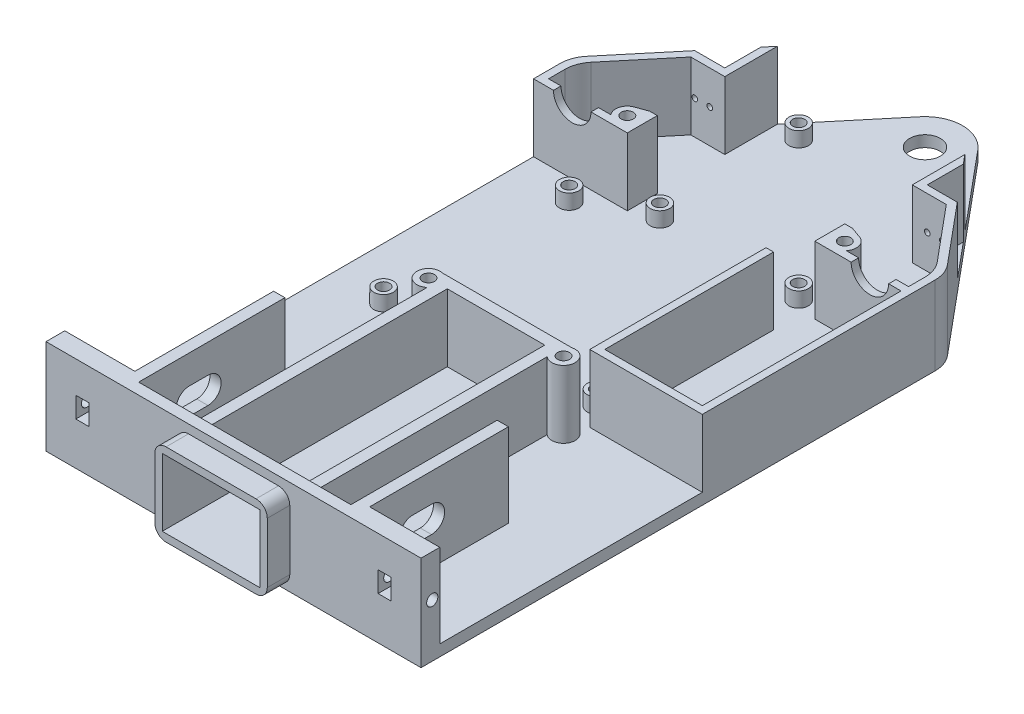
from build123d import *

# Parameters (mm, degrees)
SKETCH1_W            = 100
SKETCH1_H            = 140
BOSS_EXTRUDE1_DEPTH  = 3
BOSS_EXTRUDE2_DEPTH  = 22.3
SKETCH4_W            = 3.5
SKETCH4_H            = 5.5
CUT_EXTRUDE2_DEPTH   = 5
CUT_EXTRUDE1_START   = -3
SKETCH3_R            = 1.5
CUT_EXTRUDE1_DEPTH   = 22.7
BOSS_EXTRUDE3_DEPTH  = 18
BOSS_EXTRUDE4_DEPTH  = 3
SKETCH7_W            = 26
SKETCH7_H            = 18
BOSS_EXTRUDE5_DEPTH  = 6
BOSS_EXTRUDE8_DEPTH  = 3
SKETCH9_R            = 2.6
SKETCH9_R_2          = 1.6
BOSS_EXTRUDE7_DEPTH  = 4
BOSS_EXTRUDE9_DEPTH  = 18
SKETCH13_R           = 1.6
BOSS_EXTRUDE10_DEPTH = 18
CUT_EXTRUDE3_REACH   = 5
SKETCH12_R           = 4.1
SKETCH14_R           = 0.75
CUT_EXTRUDE4_DEPTH   = 2
CUT_EXTRUDE5_DEPTH   = 2
FILLET2_R            = 8


with BuildPart() as part:
    # Sketch1 → Boss-Extrude1 (new body)
    with BuildSketch(Plane(origin=(0, 0, 0), x_dir=(1, 0, 0), z_dir=(0, 1, 0))):
        Rectangle(SKETCH1_W, SKETCH1_H)
    extrude(amount=BOSS_EXTRUDE1_DEPTH)

    # Sketch2 → Boss-Extrude2 (add)
    with BuildSketch(Plane(origin=(0, 3, 0), x_dir=(1, 0, 0), z_dir=(0, 1, 0))):
        Polygon((-50, -65), (-50, -70), (-28.3, -70), (-28.3, -28), (-31.3, -28), (-31.3, -65), align=None)
    boss_extrude2 = extrude(amount=BOSS_EXTRUDE2_DEPTH)

    # Sketch4 → Cut-Extrude2 (cut)
    with BuildSketch(Plane(origin=(0, 0, 65), x_dir=(-1, 0, 0), z_dir=(0, 0, -1))):
        with Locations((40.3, 14.15)):
            Rectangle(SKETCH4_W, SKETCH4_H)
    cut_extrude2 = extrude(amount=-CUT_EXTRUDE2_DEPTH, mode=Mode.SUBTRACT)

    # Sketch3 → Cut-Extrude1 (cut)
    with BuildSketch(Plane.ZY.offset(31.3).offset(CUT_EXTRUDE1_START)):
        with Locations((67, 14.15)):
            Circle(SKETCH3_R)
        with BuildLine():
            Line((53.5, 10.65), (48.5, 10.65))
            ThreePointArc((48.5, 10.65), (45, 14.15), (48.5, 17.65))
            Line((48.5, 17.65), (53.5, 17.65))
            ThreePointArc((53.5, 17.65), (57, 14.15), (53.5, 10.65))
        make_face()
    cut_extrude1 = extrude(amount=CUT_EXTRUDE1_DEPTH, mode=Mode.SUBTRACT)

    # Mirror1: Boss-Extrude2, Cut-Extrude2, Cut-Extrude1 across plane
    add(boss_extrude2.mirror(Plane(origin=(0, 0, 0), x_dir=(0, 0, 1), z_dir=(1, 0, 0))))
    add(cut_extrude2.mirror(Plane(origin=(0, 0, 0), x_dir=(0, 0, 1), z_dir=(1, 0, 0))), mode=Mode.SUBTRACT)
    add(cut_extrude1.mirror(Plane(origin=(0, 0, 0), x_dir=(0, 0, 1), z_dir=(1, 0, 0))), mode=Mode.SUBTRACT)

    # Sketch5 → Boss-Extrude3 (add)
    with BuildSketch(Plane(origin=(0, 3, 0), x_dir=(1, 0, 0), z_dir=(0, 1, 0))):
        Polygon((13, -70), (16, -70), (16, 3), (-16, 3), (-16, -70), (-13, -70), (-13, 0), (13, 0), align=None)
    extrude(amount=BOSS_EXTRUDE3_DEPTH)

    # Sketch6 → Boss-Extrude4 (add)
    with BuildSketch(Plane.XY.offset(70)):
        Polygon((28.3, 25.3), (28.3, 3), (16, 3), (16, 21), (13, 21), (-13, 21), (-16, 21), (-16, 3), (-28.3, 3), (-28.3, 25.3), align=None)
    extrude(amount=-BOSS_EXTRUDE4_DEPTH)

    # Sketch7 → Boss-Extrude5 (add)
    with BuildSketch(Plane.XY.offset(70)):
        with BuildLine():
            Line((-12, 23), (12, 23))
            ThreePointArc((12, 23), (14.121320344, 22.121320344), (15, 20))
            Line((15, 20), (15, 4))
            ThreePointArc((15, 4), (14.121320344, 1.878679656), (12, 1))
            Line((12, 1), (-12, 1))
            ThreePointArc((-12, 1), (-14.121320344, 1.878679656), (-15, 4))
            Line((-15, 4), (-15, 20))
            ThreePointArc((-15, 20), (-14.121320344, 22.121320344), (-12, 23))
        make_face()
        with Locations((0, 12)):
            Rectangle(SKETCH7_W, SKETCH7_H, mode=Mode.SUBTRACT)
    extrude(amount=BOSS_EXTRUDE5_DEPTH)

    # Sketch10 → Boss-Extrude8 (add)
    with BuildSketch(Plane(origin=(0, 3, 0), x_dir=(1, 0, 0), z_dir=(0, 1, 0))):
        Polygon((50, 70), (-50, 70), (0, 130), align=None)
    extrude(amount=-BOSS_EXTRUDE8_DEPTH)

    # Sketch9 → Boss-Extrude7 (add)
    with BuildSketch(Plane(origin=(0, 3, 0), x_dir=(1, 0, 0), z_dir=(0, 1, 0))):
        with Locations((-34.7, 54.2)):
            Circle(SKETCH9_R)
        with Locations((-34.7, 54.2)):
            Circle(SKETCH9_R_2, mode=Mode.SUBTRACT)
        with Locations((-36, 6)):
            Circle(SKETCH9_R)
        with Locations((-36, 6)):
            Circle(SKETCH9_R_2, mode=Mode.SUBTRACT)
        with Locations((16.1, 10.8)):
            Circle(SKETCH9_R)
        with Locations((16.1, 10.8)):
            Circle(SKETCH9_R_2, mode=Mode.SUBTRACT)
        with Locations((16.1, 38.7)):
            Circle(SKETCH9_R)
        with Locations((16.1, 38.7)):
            Circle(SKETCH9_R_2, mode=Mode.SUBTRACT)
        with Locations((-18.5, 62.2)):
            Circle(SKETCH9_R)
        with Locations((-18.5, 62.2)):
            Circle(SKETCH9_R_2, mode=Mode.SUBTRACT)
        with Locations((-18.5, 99.2)):
            Circle(SKETCH9_R)
        with Locations((-18.5, 99.2)):
            Circle(SKETCH9_R_2, mode=Mode.SUBTRACT)
        with Locations((18.5, 99.2)):
            Circle(SKETCH9_R)
        with Locations((18.5, 99.2)):
            Circle(SKETCH9_R_2, mode=Mode.SUBTRACT)
        with Locations((18.5, 62.2)):
            Circle(SKETCH9_R)
        with Locations((18.5, 62.2)):
            Circle(SKETCH9_R_2, mode=Mode.SUBTRACT)
    extrude(amount=BOSS_EXTRUDE7_DEPTH)

    # Sketch11 → Boss-Extrude9 (add)
    with BuildSketch(Plane(origin=(0, 3, 0), x_dir=(1, 0, 0), z_dir=(0, 1, 0))):
        Polygon((50, 5), (50, 70), (35, 88), (27, 88), (27, 97.6), (25, 100), (25, 96.87590013), (25, 86), (27, 86), (34.063250108, 86), (48, 69.27590013), (48, 62), (27, 62), (27, 68), (25, 68), (25, 60), (48, 60), (48, 7), (22, 7), (22, 52), (20, 52), (20, 5), align=None)
        Polygon((-50, 70), (-50, 60), (-25, 60), (-25, 68), (-27, 68), (-27, 62), (-48, 62), (-48, 69.27590013), (-34.063250108, 86), (-27, 86), (-25, 86), (-25, 96.87590013), (-25, 100), (-27, 97.6), (-27, 88), (-35, 88), align=None)
    extrude(amount=BOSS_EXTRUDE9_DEPTH)

    # Sketch13 → Boss-Extrude10 (add)
    with BuildSketch(Plane(origin=(0, 3, 0), x_dir=(1, 0, 0), z_dir=(0, 1, 0))):
        with BuildLine():
            Line((16, 2.368543856), (16, 3))
            Line((16, 3), (17.218975032, 3))
            ThreePointArc((17.218975032, 3), (19.425906443, -2.752597104), (16, 2.368543856))
        make_face()
        with Locations((18, 0)):
            Circle(SKETCH13_R, mode=Mode.SUBTRACT)
        with BuildLine():
            Line((27, 66.368543856), (27, 68))
            Line((27, 68), (30.037478421, 66.921239211))
            ThreePointArc((30.037478421, 66.921239211), (29.554959445, 60.950078687), (27, 66.368543856))
        make_face()
        with Locations((29, 64)):
            Circle(SKETCH13_R, mode=Mode.SUBTRACT)
    boss_extrude10 = extrude(amount=BOSS_EXTRUDE10_DEPTH)

    # Sketch12 → Cut-Extrude3 (cut, up to next)
    with BuildSketch(Plane(origin=(0, 3, 0), x_dir=(1, 0, 0), z_dir=(0, 1, 0)), mode=Mode.PRIVATE) as cut_extrude3_sk1:
        with Locations((0, 114.379500648)):
            Circle(SKETCH12_R)
    cut_extrude3_tool1 = extrude(cut_extrude3_sk1.sketch, amount=-CUT_EXTRUDE3_REACH, mode=Mode.PRIVATE) & part.part
    add(cut_extrude3_tool1.solids().sort_by_distance((0, 3, -114.379501))[0], mode=Mode.SUBTRACT)
    # Sketch12 → Cut-Extrude3 (cut, up to next)
    with BuildSketch(Plane(origin=(0, 3, 0), x_dir=(1, 0, 0), z_dir=(0, 1, 0)), mode=Mode.PRIVATE) as cut_extrude3_sk2:
        with BuildLine():
            Line((7.682212796, 120.781344645), (0, 130))
            Line((0, 130), (-7.682212796, 120.781344645))
            ThreePointArc((-7.682212796, 120.781344645), (0, 124.379500648), (7.682212796, 120.781344645))
        make_face()
    cut_extrude3_tool2 = extrude(cut_extrude3_sk2.sketch, amount=-CUT_EXTRUDE3_REACH, mode=Mode.PRIVATE) & part.part
    add(cut_extrude3_tool2.solids().sort_by_distance((0, 3, -125.762596))[0], mode=Mode.SUBTRACT)

    # Sketch14 → Cut-Extrude4 (cut)
    with BuildSketch(Plane(origin=(0, 0, -88), x_dir=(-1, 0, 0), z_dir=(0, 0, -1))):
        with Locations((-29, 12)):
            Circle(SKETCH14_R)
        with Locations((-33, 12)):
            Circle(SKETCH14_R)
    cut_extrude4 = extrude(amount=-CUT_EXTRUDE4_DEPTH, mode=Mode.SUBTRACT)

    # Sketch15 → Cut-Extrude5 (cut)
    with BuildSketch(Plane(origin=(0, 0, -62), x_dir=(-1, 0, 0), z_dir=(0, 0, -1))):
        with BuildLine():
            Line((-44.684271928, 21), (-34.684271928, 21))
            ThreePointArc((-34.684271928, 21), (-39.684271928, 16), (-44.684271928, 21))
        make_face()
    cut_extrude5 = extrude(amount=-CUT_EXTRUDE5_DEPTH, mode=Mode.SUBTRACT)

    # Fillet2
    fillet2_edges = [part.edges().sort_by_distance(p)[0] for p in [
        (48, 12, -69.27590013),
        (-48, 12, -69.27590013),
        (-50, 10.5, -70),
        (50, 10.5, -70),
    ]]
    fillet(fillet2_edges, radius=FILLET2_R)

    # Mirror2: Boss-Extrude10, Cut-Extrude4, Cut-Extrude5 across plane
    add(boss_extrude10.mirror(Plane(origin=(0, 0, 0), x_dir=(0, 0, 1), z_dir=(1, 0, 0))))
    add(cut_extrude4.mirror(Plane(origin=(0, 0, 0), x_dir=(0, 0, 1), z_dir=(1, 0, 0))), mode=Mode.SUBTRACT)
    add(cut_extrude5.mirror(Plane(origin=(0, 0, 0), x_dir=(0, 0, 1), z_dir=(1, 0, 0))), mode=Mode.SUBTRACT)


solid = part.part
